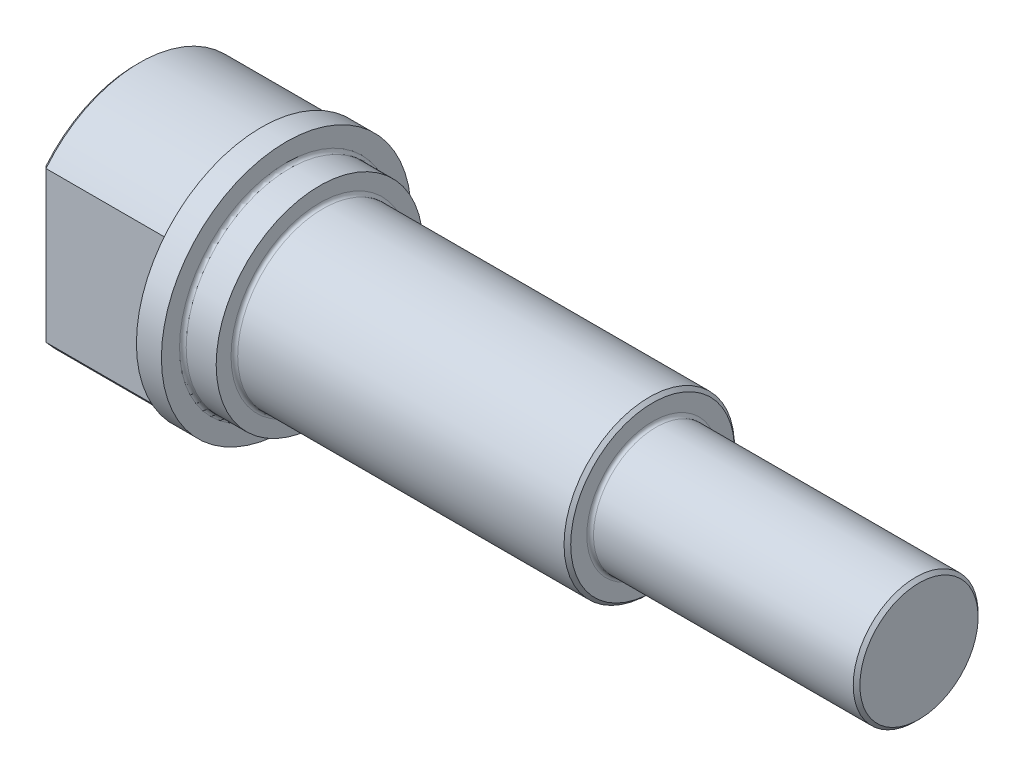
from build123d import *

# Parameters (mm, degrees)
CUT_EXTRUDE1_DEPTH = 9.525
CHAMFER1_SIZE      = 0.254
FILLET1_R          = 0.254


with BuildPart() as part:
    # Sketch1 → Revolve1 (revolve)
    with BuildSketch(Plane.XY):
        Polygon((0, 9.1694), (9.525, 9.1694), (9.525, 9.525), (11.43, 9.525), (11.43, 7.8867), (13.97, 7.8867), (13.97, 6.5), (39.37, 6.5), (39.37, 4.7625), (59.69, 4.7625), (59.69, 0), (0.635, 0), (0, 1.099852263), align=None)
    revolve(axis=Axis((0, 0, 0), (1, 0, 0)))

    # Sketch2 → Cut-Extrude1 (cut)
    with BuildSketch(Plane.ZY):
        with BuildLine():
            Line((-7.1501, -5.740554533), (-7.1501, 5.740554533))
            ThreePointArc((-7.1501, 5.740554533), (-9.1694, 0), (-7.1501, -5.740554533))
        make_face()
        with BuildLine():
            Line((7.1501, -5.740554533), (7.1501, 5.740554533))
            ThreePointArc((7.1501, 5.740554533), (9.1694, 0), (7.1501, -5.740554533))
        make_face()
    extrude(amount=-CUT_EXTRUDE1_DEPTH, mode=Mode.SUBTRACT)

    # Chamfer1
    chamfer1_edges = [part.edges().sort_by_distance(p)[0] for p in [
        (0, 9.1694, 0),
        (39.37, -6.5, 0),
        (0, 0, 7.1501),
        (0, -9.1694, 0),
        (0, 0, -7.1501),
        (59.69, -4.7625, 0),
    ]]
    chamfer(chamfer1_edges, length=CHAMFER1_SIZE)

    # Fillet1
    fillet1_edges = [part.edges().sort_by_distance(p)[0] for p in [
        (9.525, 9.1694, 0),
        (11.43, -7.8867, 0),
        (13.97, -6.5, 0),
        (9.525, 0, 7.1501),
        (9.525, -9.1694, 0),
        (9.525, 0, -7.1501),
        (39.37, -4.7625, 0),
    ]]
    fillet(fillet1_edges, radius=FILLET1_R)


solid = part.part
